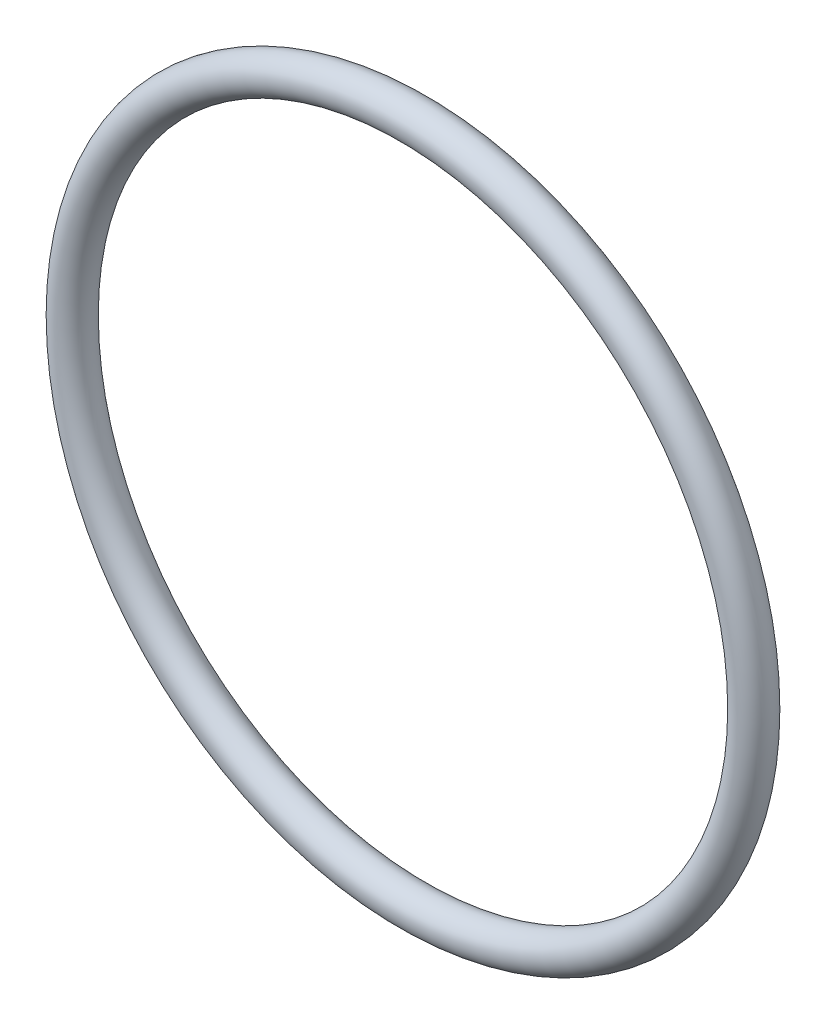
from build123d import *

# Parameters (mm, degrees)
SKETCH1_R = 1.3081


with BuildPart() as part:
    # Sketch1 → Revolve1 (revolve)
    with BuildSketch(Plane(origin=(0, 0, 0), x_dir=(0, 0, -1), z_dir=(1, 0, 0))):
        with Locations((0, 24.1554)):
            Circle(SKETCH1_R)
    revolve(axis=Axis((0, 0, 18.132319356), (0, 0, -1)))


solid = part.part
